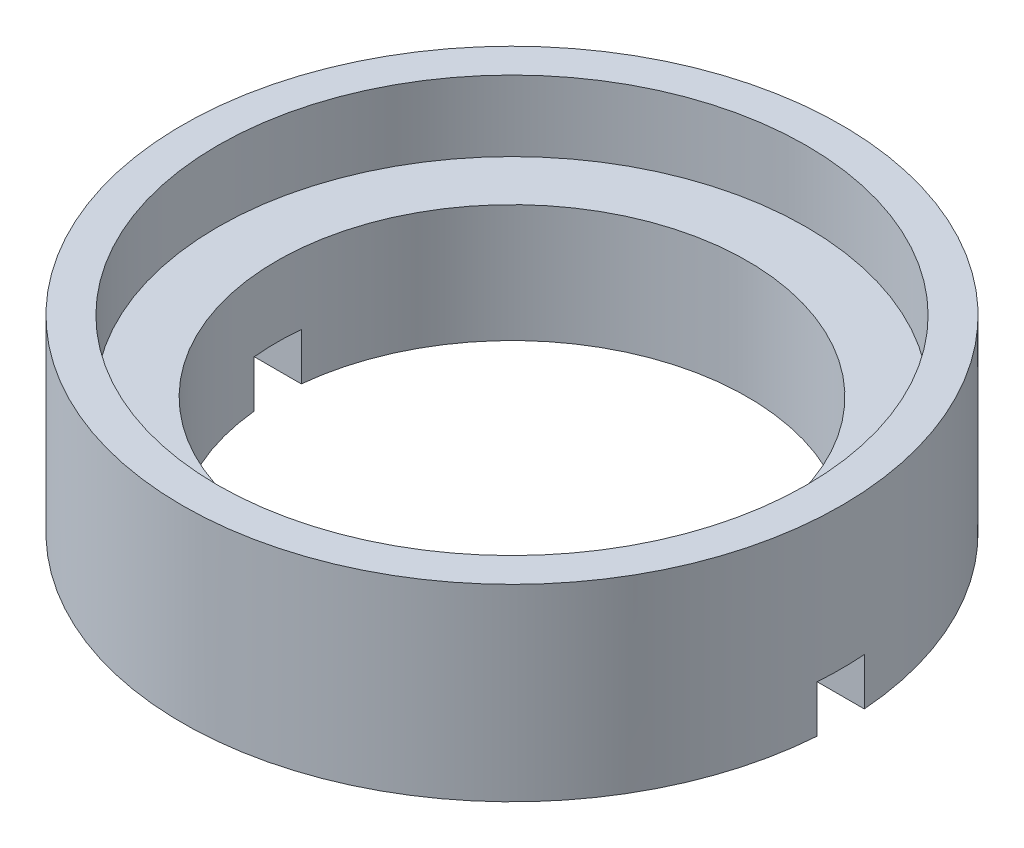
from build123d import *

# Parameters (mm, degrees)
SKETCH1_R           = 7
BOSS_EXTRUDE1_DEPTH = 4
SKETCH2_R           = 6.25
CUT_EXTRUDE1_DEPTH  = 1.5
SKETCH3_R           = 5
CUT_EXTRUDE2_DEPTH  = 5
SKETCH4_W           = 16
SKETCH4_H           = 1
CUT_EXTRUDE3_DEPTH  = 1


with BuildPart() as part:
    # Sketch1 → Boss-Extrude1 (new body)
    with BuildSketch(Plane(origin=(0, 0, 0), x_dir=(1, 0, 0), z_dir=(0, 1, 0))):
        Circle(SKETCH1_R)
    extrude(amount=BOSS_EXTRUDE1_DEPTH)

    # Sketch2 → Cut-Extrude1 (cut)
    with BuildSketch(Plane(origin=(0, 4, 0), x_dir=(1, 0, 0), z_dir=(0, 1, 0))):
        Circle(SKETCH2_R)
    extrude(amount=-CUT_EXTRUDE1_DEPTH, mode=Mode.SUBTRACT)

    # Sketch3 → Cut-Extrude2 (cut, through all)
    with BuildSketch(Plane.XZ):
        Circle(SKETCH3_R)
    extrude(amount=-CUT_EXTRUDE2_DEPTH, mode=Mode.SUBTRACT)

    # Sketch4 → Cut-Extrude3 (cut)
    with BuildSketch(Plane.XZ):
        Rectangle(SKETCH4_W, SKETCH4_H)
    extrude(amount=-CUT_EXTRUDE3_DEPTH, mode=Mode.SUBTRACT)


solid = part.part
